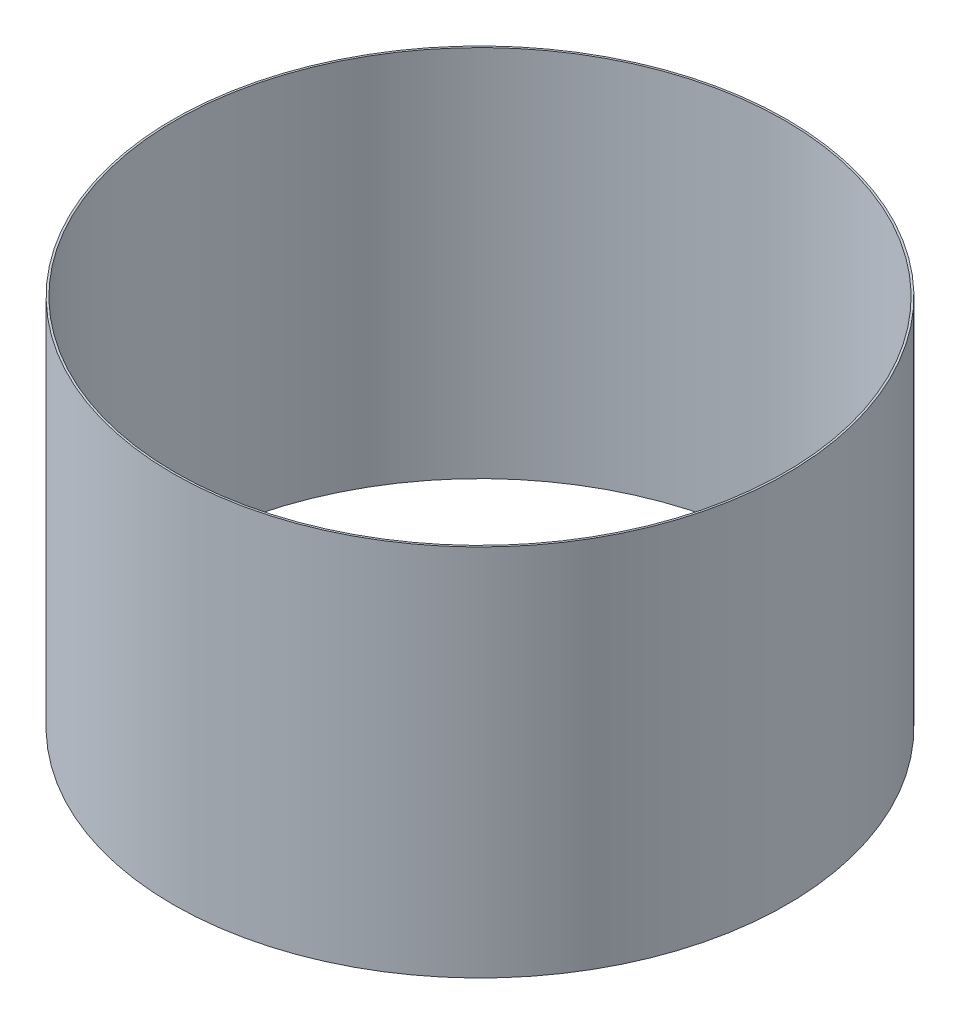
from build123d import *

# Parameters (mm, degrees)
SKETCH1_R           = 125.25375
BOSS_EXTRUDE1_DEPTH = 152.4
SKETCH3_R           = 124.46
CUT_EXTRUDE1_DEPTH  = 153.4


with BuildPart() as part:
    # Sketch1 → Boss-Extrude1 (new body)
    with BuildSketch(Plane(origin=(0, 0, 0), x_dir=(1, 0, 0), z_dir=(0, 1, 0))):
        Circle(SKETCH1_R)
    extrude(amount=BOSS_EXTRUDE1_DEPTH)

    # Sketch3 → Cut-Extrude1 (cut, through all)
    with BuildSketch(Plane.XZ):
        Circle(SKETCH3_R)
    extrude(amount=-CUT_EXTRUDE1_DEPTH, mode=Mode.SUBTRACT)


solid = part.part
